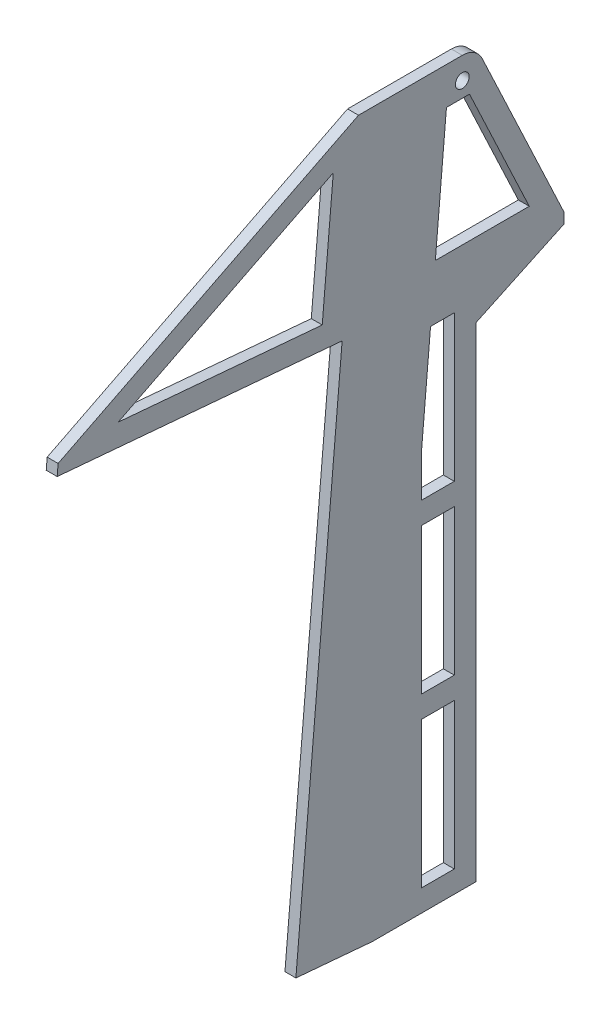
from build123d import *

# Parameters (mm, degrees)
BOSS_EXTRUDE1_DEPTH = 6.35
SKETCH2_W           = 19.05
SKETCH2_H           = 84.666666666
SKETCH2_H_2         = 84.666666667
CUT_EXTRUDE4_DEPTH  = 7.35
FILLET1_R           = 12.7
SKETCH3_R           = 4
CUT_EXTRUDE5_DEPTH  = 7.35


with BuildPart() as part:
    # Sketch1 → Boss-Extrude1 (new body)
    with BuildSketch(Plane(origin=(0, 0, 0), x_dir=(0, 0, -1), z_dir=(1, 0, 0))):
        Polygon((-138.117194795, 324.971426047), (27.166192695, 310.511003372), (0.338937449, 3.874072765), (44.619791779, 0), (104.922607749, 0), (104.922607749, 280.894117647), (155.722607749, 304.8), (155.722607749, 311.15), (104.922607749, 419.1), (36.666498884, 419.1), (-137.563755829, 331.29726238), align=None)
    extrude(amount=BOSS_EXTRUDE1_DEPTH)

    # Sketch2 → Cut-Extrude4 (cut, through all)
    with BuildSketch(Plane(origin=(6.35, 0, 0), x_dir=(0, 0, -1), z_dir=(1, 0, 0))):
        Polygon((-102.740376399, 334.624867423), (22.028376277, 397.501651207), (15.621397962, 324.269553971), align=None)
        Polygon((87.678193652, 397.501651207), (81.234509121, 323.85), (135.710176178, 323.85), (101.05057561, 397.501651207), align=None)
        Polygon((78.456744054, 292.1), (73.172607749, 231.702045651), (73.172607749, 207.433333333), (92.222607749, 207.433333333), (92.222607749, 292.1), align=None)
        with Locations((82.697607749, 152.4)):
            Rectangle(SKETCH2_W, SKETCH2_H)
        with Locations((82.697607749, 55.033333334)):
            Rectangle(SKETCH2_W, SKETCH2_H_2)
    extrude(amount=-CUT_EXTRUDE4_DEPTH, mode=Mode.SUBTRACT)

    # Fillet1
    fillet1_edges = [part.edges().sort_by_distance(p)[0] for p in [
        (3.175, 419.1, -104.922607749),
    ]]
    fillet(fillet1_edges, radius=FILLET1_R)

    # Sketch3 → Cut-Extrude5 (cut, through all)
    with BuildSketch(Plane(origin=(6.35, 0, 0), x_dir=(0, 0, -1), z_dir=(1, 0, 0))):
        with Locations((96.863117355, 406.4)):
            Circle(SKETCH3_R)
    extrude(amount=-CUT_EXTRUDE5_DEPTH, mode=Mode.SUBTRACT)


solid = part.part
